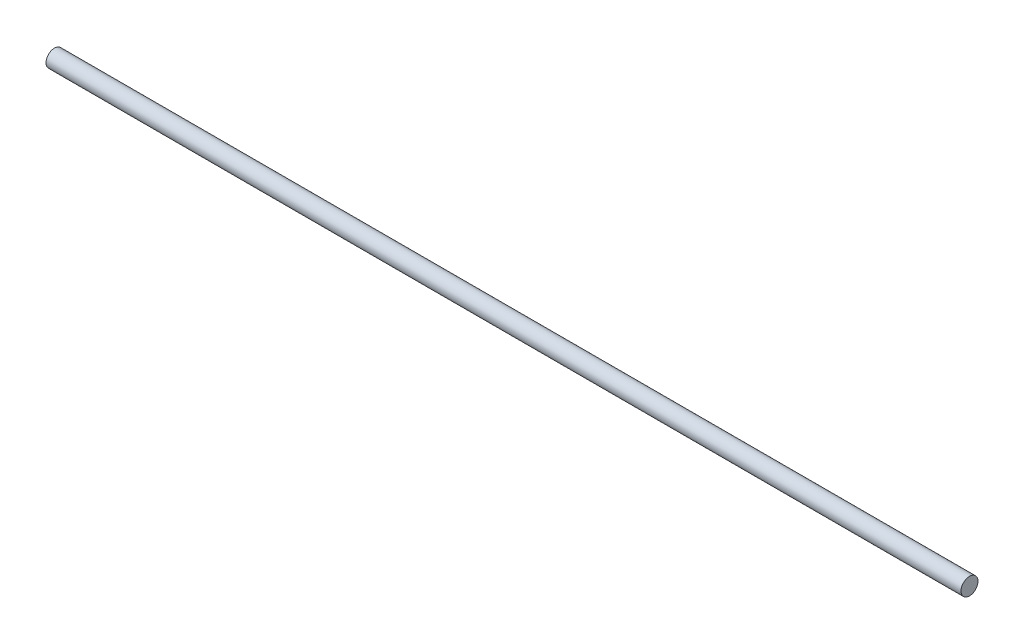
from build123d import *

# Parameters (mm, degrees)
SKETCH1_R           = 6.35
BOSS_EXTRUDE1_DEPTH = 683.514


with BuildPart() as part:
    # Sketch1 → Boss-Extrude1 (new body)
    with BuildSketch(Plane(origin=(0, 0, 0), x_dir=(0, 0, -1), z_dir=(1, 0, 0))):
        Circle(SKETCH1_R)
    extrude(amount=BOSS_EXTRUDE1_DEPTH)


solid = part.part
